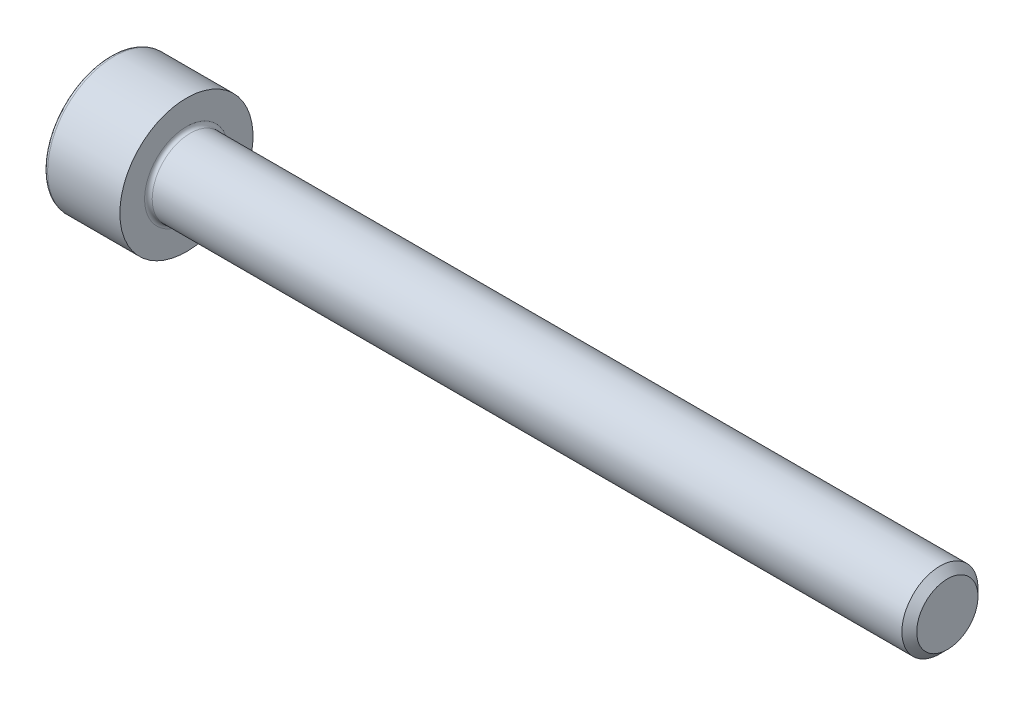
from build123d import *

# Parameters (mm, degrees)
FILLET1_R   = 0.2
FILLET2_R   = 0.2
HEX_2_DEPTH = 2


with BuildPart() as part:
    # BodySke → Base-Revolve (revolve)
    with BuildSketch(Plane.XY):
        Polygon((0, 0), (0, 3.5), (4, 3.5), (4, 2), (43.61, 2), (44, 1.61), (44, 0), align=None)
    revolve(axis=Axis((-31.75, 0, 0), (1, 0, 0)))

    # Fillet1
    fillet1_edges = [part.edges().sort_by_distance(p)[0] for p in [
        (4, -2, 0),
    ]]
    fillet(fillet1_edges, radius=FILLET1_R)

    # Fillet2
    fillet2_edges = [part.edges().sort_by_distance(p)[0] for p in [
        (0, -3.5, 0),
    ]]
    fillet(fillet2_edges, radius=FILLET2_R)

    # Sketch2 → Hex-PreBroach (revolve, cut)
    with BuildSketch(Plane.XY):
        Polygon((0, 1.5355), (2, 1.5355), (2.886521338, 0), (0, 0), align=None)
    revolve(axis=Axis((0, 0, 0), (1, 0, 0)), mode=Mode.SUBTRACT)

    # Sketch3 → Hex 2 (cut)
    with BuildSketch(Plane(origin=(0, 0, 0), x_dir=(0, 0.5, 0.866025404), z_dir=(-1, 0, 0))):
        Polygon((0.886521338, 1.5355), (-0.886521338, 1.5355), (-1.773042677, 0), (-0.886521338, -1.5355), (0.886521338, -1.5355), (1.773042677, 0), align=None)
    extrude(amount=-HEX_2_DEPTH, mode=Mode.SUBTRACT)


solid = part.part
